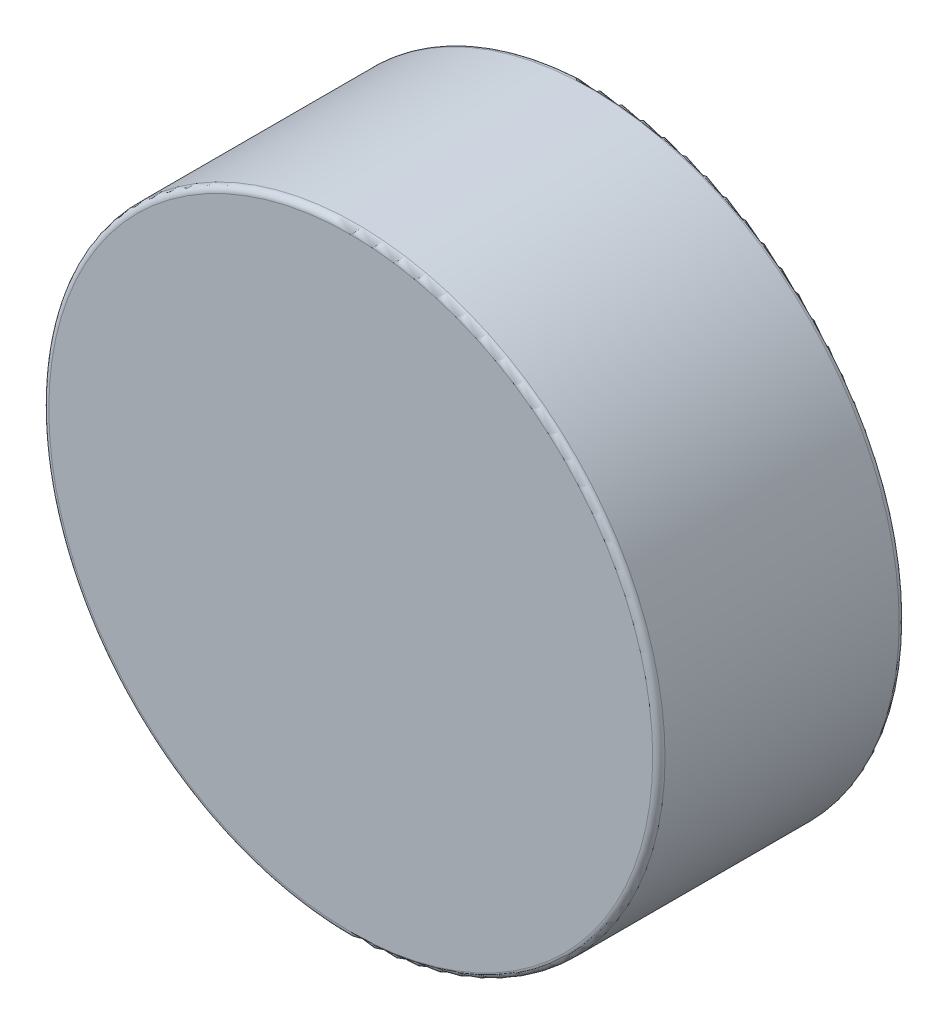
from build123d import *

# Parameters (mm, degrees)
SKETCH3_R                = 3.175
BOSS_EXTRUDE1_DEPTH      = 1.27
BOSS_EXTRUDE1_DEPTH_BACK = 1.27
FILLET1_R                = 0.0635


with BuildPart() as part:
    # Sketch3 → Boss-Extrude1 (new body, two sides)
    with BuildSketch(Plane.XY) as boss_extrude1_sk:
        Circle(SKETCH3_R)
    extrude(amount=BOSS_EXTRUDE1_DEPTH)
    extrude(boss_extrude1_sk.sketch, amount=-BOSS_EXTRUDE1_DEPTH_BACK)

    # Fillet1
    fillet1_edges = [part.edges().sort_by_distance(p)[0] for p in [
        (-3.175, 0, -1.27),
        (-3.175, 0, 1.27),
    ]]
    fillet(fillet1_edges, radius=FILLET1_R)


solid = part.part
